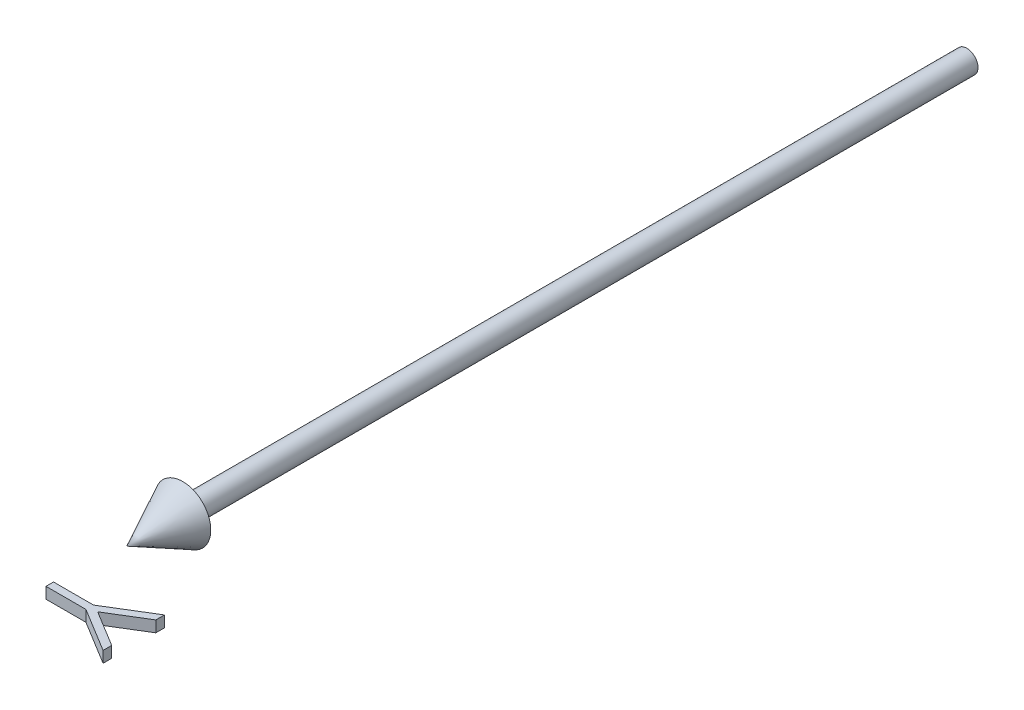
from build123d import *

# Parameters (mm, degrees)
BOSS_EXTRUDE1_DEPTH      = 1
BOSS_EXTRUDE1_DEPTH_BACK = 1


with BuildPart() as part:
    # Sketch2 → Revolve1 (revolve)
    with BuildSketch(Plane(origin=(0, 0, 0), x_dir=(1, 0, 0), z_dir=(0, 1, 0))):
        Polygon((0, -150), (5, -140), (2, -140), (2, 0), (0, 0), align=None)
    revolve(axis=Axis((0, 0, -41.949952025), (0, 0, 1)))


with BuildPart() as body_2:
    # Sketch3 → Boss-Extrude1 (new, two sides: drawn at the far end of the back side and taken through both)
    with BuildSketch(Plane(origin=(0, 0, 0), x_dir=(1, 0, 0), z_dir=(0, 1, 0)).offset(-BOSS_EXTRUDE1_DEPTH_BACK)):
        Polygon((15, -158.269230769), (15, -159.810697115), (8.5546875, -163.753004808), (15, -167.689302885), (15, -169.230769231), (7.130408654, -164.423076923), (0, -164.423076923), (0, -163.076923077), (7.130408654, -163.076923077), align=None)
    extrude(amount=BOSS_EXTRUDE1_DEPTH + BOSS_EXTRUDE1_DEPTH_BACK)


solid = Compound([part.part, body_2.part])
